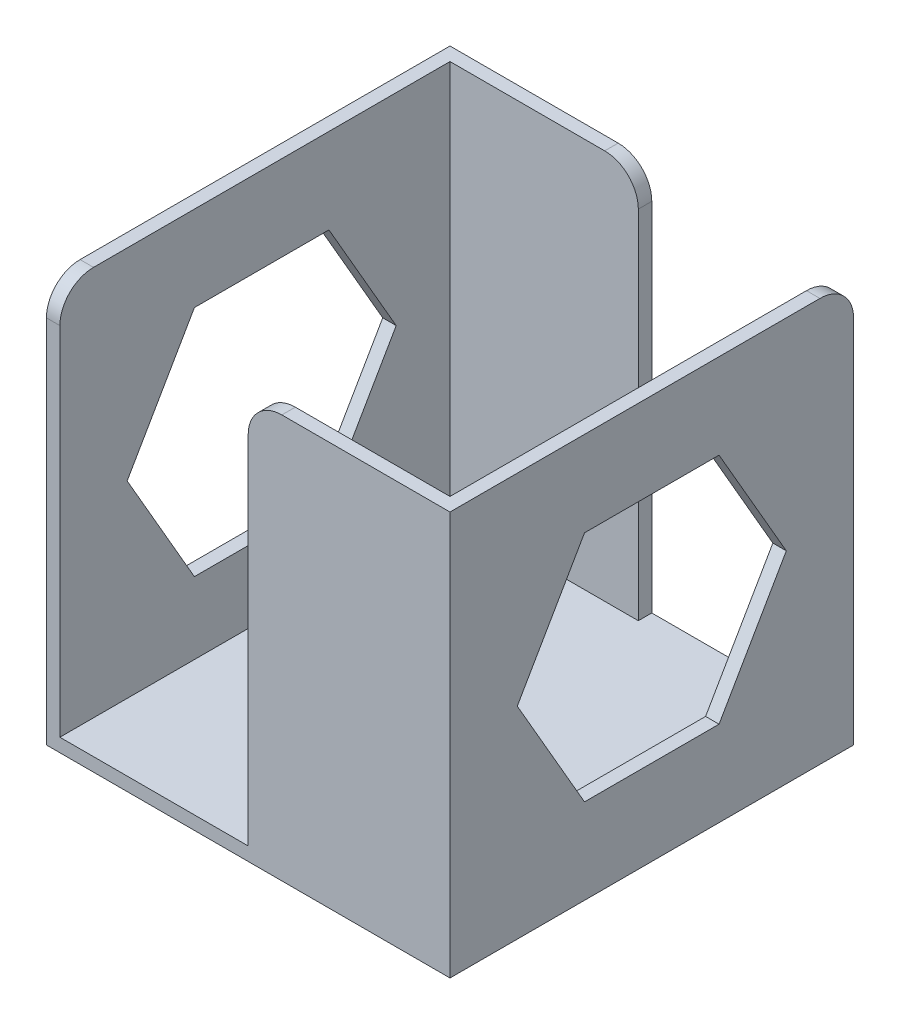
from build123d import *

# Parameters (mm, degrees)
SKETCH1_W           = 60
SKETCH1_H           = 60
CUBE_DEPTH          = 60
SHELL1_T            = -2
SKETCH2_W           = 28
SKETCH2_H           = 58
CUT_OUT_LEFT_DEPTH  = 2
CUT_OUT_RIGHT_REACH = 62
SKETCH3_W           = 28
SKETCH3_H           = 58
HEX_CUT_DEPTH       = 61
FILLET1_R           = 5


with BuildPart() as part:
    # Sketch1 → Cube (new body)
    with BuildSketch(Plane(origin=(0, 0, 0), x_dir=(1, 0, 0), z_dir=(0, 1, 0))):
        Rectangle(SKETCH1_W, SKETCH1_H)
    extrude(amount=CUBE_DEPTH)

    # Shell1
    shell1_openings = [part.faces().sort_by_distance(p)[0] for p in [
        (0, 60, 0),
    ]]
    offset(amount=SHELL1_T, openings=shell1_openings, kind=Kind.INTERSECTION)

    # Sketch2 → Cut Out Left (cut)
    with BuildSketch(Plane.XY.offset(30)):
        with Locations((-14, 31)):
            Rectangle(SKETCH2_W, SKETCH2_H)
    extrude(amount=-CUT_OUT_LEFT_DEPTH, mode=Mode.SUBTRACT)

    # Sketch3 → Cut Out Right (cut, up to next)
    with BuildSketch(Plane(origin=(0, 0, -30), x_dir=(-1, 0, 0), z_dir=(0, 0, -1)), mode=Mode.PRIVATE) as cut_out_right_sk1:
        with Locations((-14, 31)):
            Rectangle(SKETCH3_W, SKETCH3_H)
    cut_out_right_tool1 = extrude(cut_out_right_sk1.sketch, amount=-CUT_OUT_RIGHT_REACH, mode=Mode.PRIVATE) & part.part
    add(cut_out_right_tool1.solids().sort_by_distance((14, 31, -30))[0], mode=Mode.SUBTRACT)

    # Sketch4 → Hex Cut (cut, through all)
    with BuildSketch(Plane(origin=(30, 0, 0), x_dir=(0, 0, -1), z_dir=(1, 0, 0))):
        Polygon((20, 30), (10, 47.320508076), (-10, 47.320508076), (-20, 30), (-10, 12.679491924), (10, 12.679491924), align=None)
    extrude(amount=-HEX_CUT_DEPTH, mode=Mode.SUBTRACT)

    # Fillet1
    fillet1_edges = [part.edges().sort_by_distance(p)[0] for p in [
        (29, 60, -30),
        (0, 60, -29),
        (0, 60, 29),
        (-29, 60, 30),
    ]]
    fillet(fillet1_edges, radius=FILLET1_R)


solid = part.part
